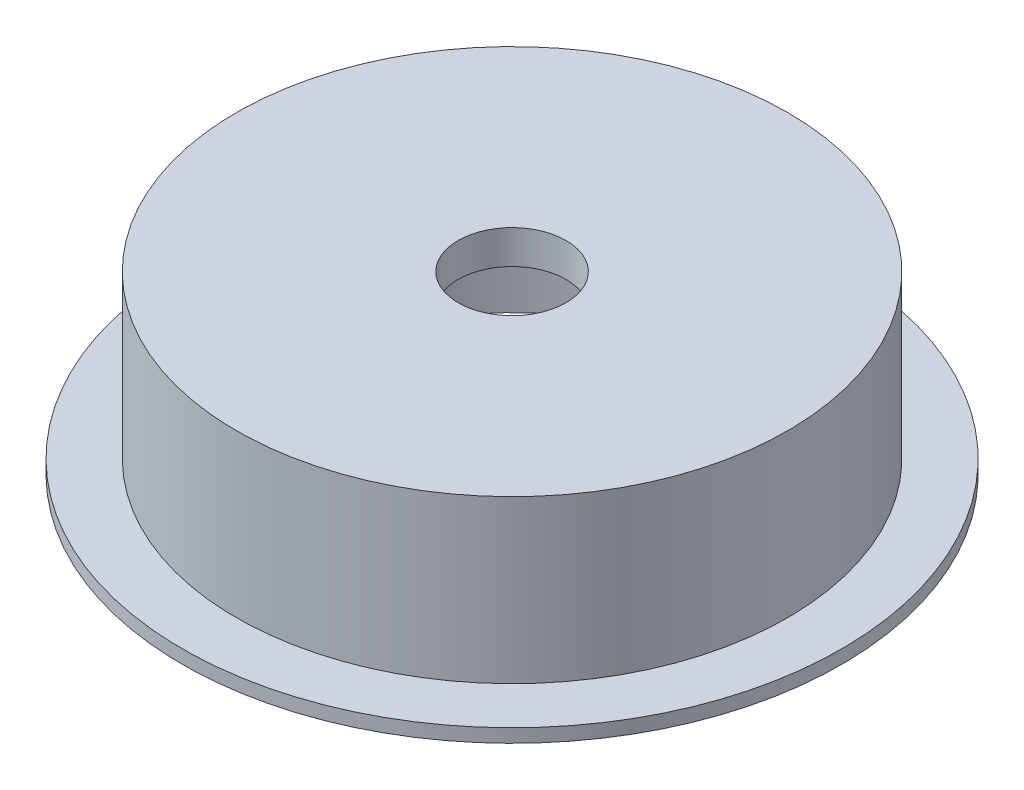
from build123d import *


with BuildPart() as part:
    # Эскиз1 → Повернуть1 (revolve)
    with BuildSketch(Plane.XY):
        Polygon((17, 0), (18, 0), (18, 1.647568474), (24.43248748, 1.647568474), (24.43248748, 2.647568474), (20.43248748, 2.647568474), (20.43248748, 14.65529647), (4, 14.65529647), (4, 12.15529647), (17, 12.15529647), align=None)
    revolve(axis=Axis((0, 0, 0), (0, 1, 0)))


solid = part.part
